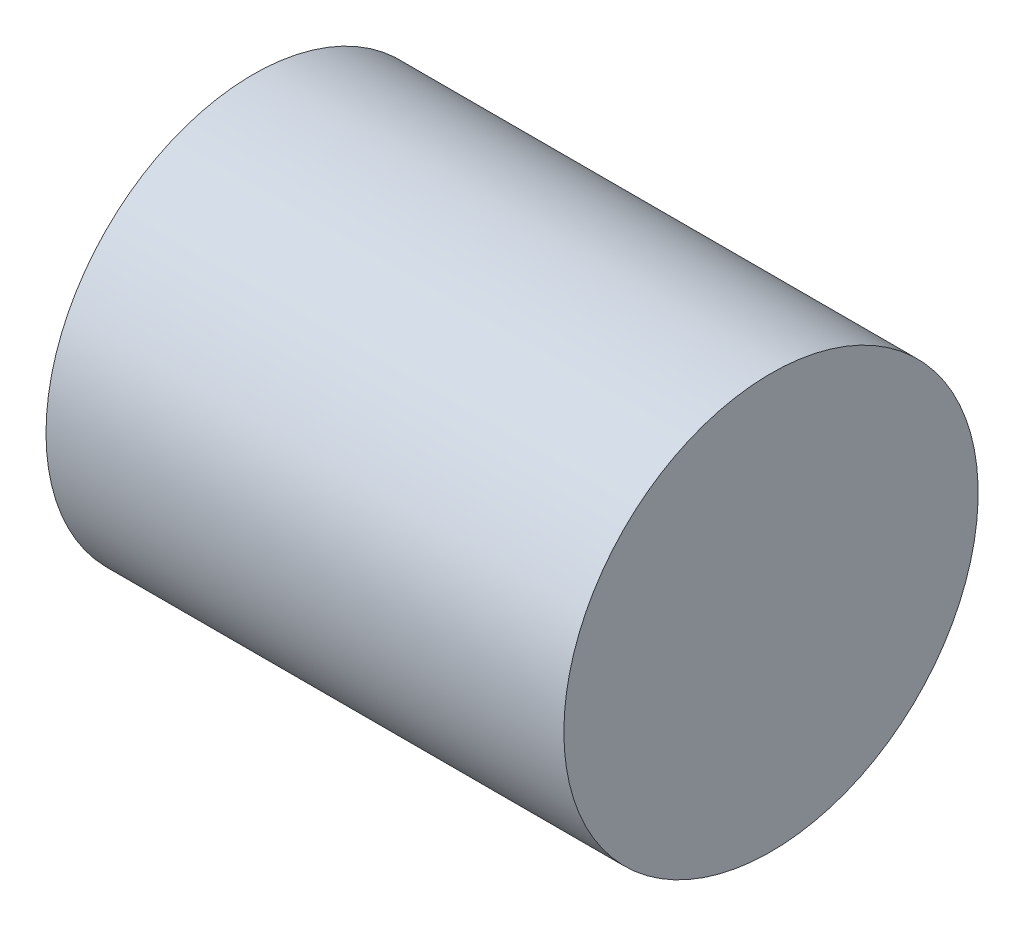
from build123d import *

# Parameters (mm, degrees)
SCHIZZO1_W = 40
SCHIZZO1_H = 16


with BuildPart() as part:
    # Schizzo1 → Rivoluzione1 (revolve)
    with BuildSketch(Plane.XY):
        with Locations((20, 8)):
            Rectangle(SCHIZZO1_W, SCHIZZO1_H)
    revolve(axis=Axis((0, 16, 0), (1, 0, 0)))


solid = part.part
